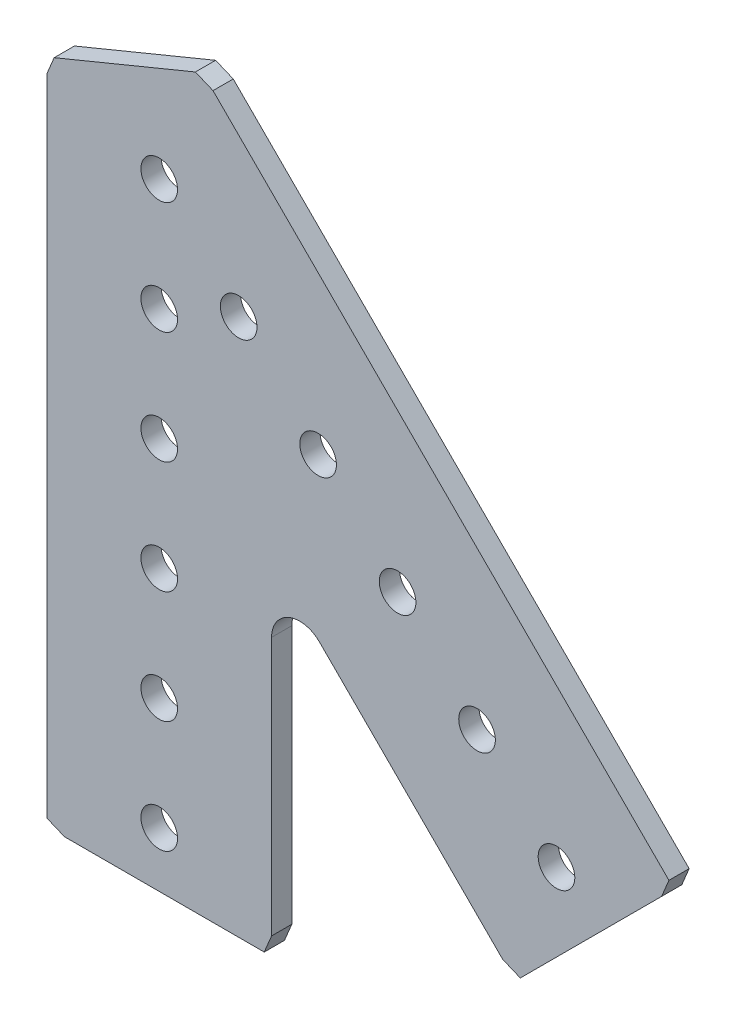
from build123d import *

# Parameters (mm, degrees)
SKETCH1_R           = 2.0701
BOSS_EXTRUDE1_DEPTH = 2.286


with BuildPart() as part:
    # Sketch1 → Boss-Extrude1 (new body)
    with BuildSketch(Plane.XY.offset(2.286)):
        with BuildLine():
            Line((-12.7, 3.956428413), (-12.7, -68.893532285))
            Line((-12.7, -68.893532285), (-10.706695129, -69.723))
            Line((-10.706695129, -69.723), (11.870532285, -69.723))
            Line((11.870532285, -69.723), (12.7, -67.729695129))
            Line((12.7, -67.729695129), (12.7, -38.505245425))
            ThreePointArc((12.7, -38.505245425), (14.659980102, -35.571927909), (18.12006403, -36.260181395))
            Line((18.12006403, -36.260181395), (38.820161129, -56.960278494))
            Line((38.820161129, -56.960278494), (40.813466, -57.789746209))
            Line((40.813466, -57.789746209), (56.780673371, -41.822538838))
            Line((56.780673371, -41.822538838), (57.610141086, -39.829233967))
            Line((57.610141086, -39.829233967), (6.081013492, 11.699893628))
            Line((6.081013492, 11.699893628), (4.087708621, 12.529361343))
            Line((4.087708621, 12.529361343), (-11.870532285, 5.949733284))
            Line((-11.870532285, 5.949733284), (-12.7, 3.956428413))
        make_face()
        with Locations((0, -63.5)):
            Circle(SKETCH1_R, mode=Mode.SUBTRACT)
        with Locations((35.921024484, -35.921024484)):
            Circle(SKETCH1_R, mode=Mode.SUBTRACT)
        with Locations((17.960512242, -17.960512242)):
            Circle(SKETCH1_R, mode=Mode.SUBTRACT)
        with Locations((0, -38.1)):
            Circle(SKETCH1_R, mode=Mode.SUBTRACT)
        with Locations((0, -12.7)):
            Circle(SKETCH1_R, mode=Mode.SUBTRACT)
        Circle(SKETCH1_R, mode=Mode.SUBTRACT)
        with Locations((8.980256121, -8.980256121)):
            Circle(SKETCH1_R, mode=Mode.SUBTRACT)
        with Locations((0, -25.4)):
            Circle(SKETCH1_R, mode=Mode.SUBTRACT)
        with Locations((0, -50.8)):
            Circle(SKETCH1_R, mode=Mode.SUBTRACT)
        with Locations((26.940768363, -26.940768363)):
            Circle(SKETCH1_R, mode=Mode.SUBTRACT)
        with Locations((44.901280605, -44.901280605)):
            Circle(SKETCH1_R, mode=Mode.SUBTRACT)
    extrude(amount=-BOSS_EXTRUDE1_DEPTH)


solid = part.part
